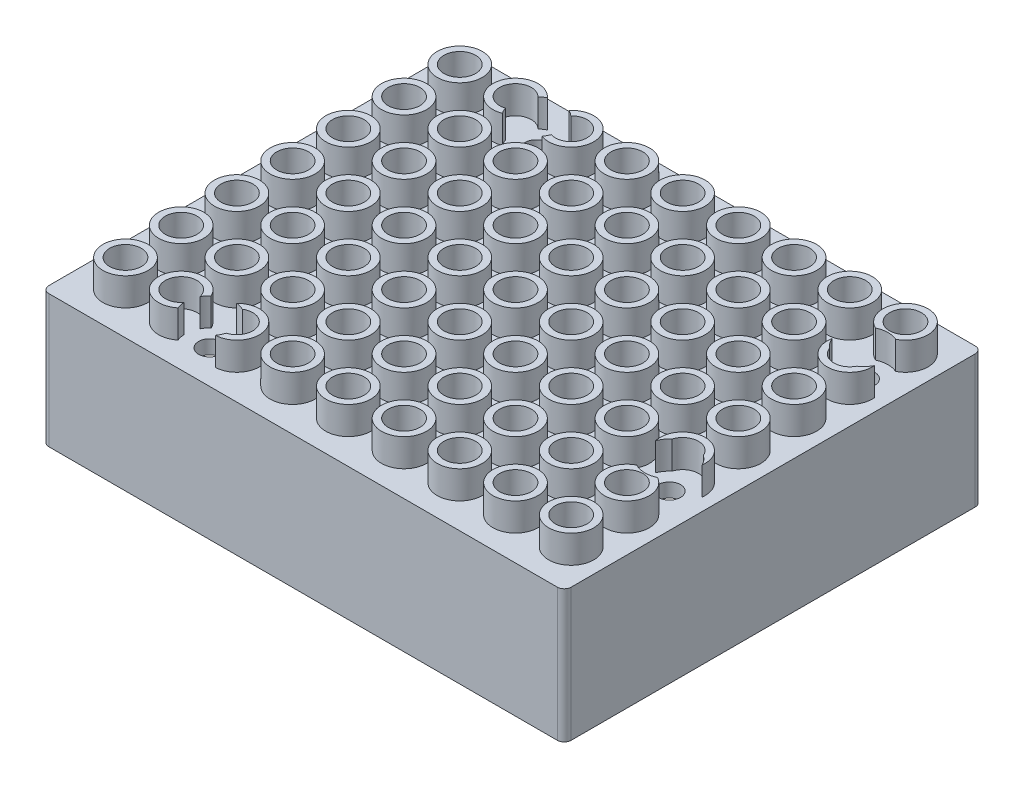
from build123d import *

# Parameters (mm, degrees)
SKETCH1_W                   = 75
SKETCH1_H                   = 60
BOSS_EXTRUDE1_DEPTH         = 19.05
FILLET1_R                   = 1
ARDUINO_START               = -2
ARDUINO_CAVITY_DEPTH        = 19.125
SKETCH4_R                   = 5.5
F_9V_BARREL_PLUG_HOLE_DEPTH = 19.125
SKETCH5_R                   = 3.2375
BUMP_1_DEPTH                = 4
SKETCH6_R                   = 2.275
CUT_EXTRUDE3_DEPTH          = 4
LPATTERN1_COUNT             = 7
LPATTERN1_PITCH             = 8
LPATTERN2_COUNT             = 9
LPATTERN2_PITCH             = 8
LPATTERN2_COPY_1_SKETCH_R   = 3.2375
LPATTERN2_COPY_1_DEPTH      = 4
LPATTERN2_COPY_2_SKETCH_R   = 3.2375
LPATTERN2_COPY_2_DEPTH      = 4
LPATTERN2_COPY_3_SKETCH_R   = 3.2375
LPATTERN2_COPY_3_DEPTH      = 4
LPATTERN2_COPY_4_SKETCH_R   = 3.2375
LPATTERN2_COPY_4_DEPTH      = 4
LPATTERN2_COPY_5_SKETCH_R   = 3.2375
LPATTERN2_COPY_5_DEPTH      = 4
LPATTERN2_COPY_6_SKETCH_R   = 3.2375
LPATTERN2_COPY_6_DEPTH      = 4
LPATTERN2_COPY_7_SKETCH_R   = 3.2375
LPATTERN2_COPY_7_DEPTH      = 4
LPATTERN2_COPY_8_SKETCH_R   = 3.2375
LPATTERN2_COPY_8_DEPTH      = 4
LPATTERN2_COPY_9_SKETCH_R   = 3.2375
LPATTERN2_COPY_9_DEPTH      = 4
LPATTERN2_COPY_10_SKETCH_R  = 3.2375
LPATTERN2_COPY_10_DEPTH     = 4
LPATTERN2_COPY_11_SKETCH_R  = 3.2375
LPATTERN2_COPY_11_DEPTH     = 4
LPATTERN2_COPY_12_SKETCH_R  = 3.2375
LPATTERN2_COPY_12_DEPTH     = 4
LPATTERN2_COPY_13_SKETCH_R  = 3.2375
LPATTERN2_COPY_13_DEPTH     = 4
LPATTERN2_COPY_14_SKETCH_R  = 3.2375
LPATTERN2_COPY_14_DEPTH     = 4
LPATTERN2_COPY_15_SKETCH_R  = 3.2375
LPATTERN2_COPY_15_DEPTH     = 4
LPATTERN2_COPY_16_SKETCH_R  = 3.2375
LPATTERN2_COPY_16_DEPTH     = 4
LPATTERN2_COPY_17_SKETCH_R  = 3.2375
LPATTERN2_COPY_17_DEPTH     = 4
LPATTERN2_COPY_18_SKETCH_R  = 3.2375
LPATTERN2_COPY_18_DEPTH     = 4
LPATTERN2_COPY_19_SKETCH_R  = 3.2375
LPATTERN2_COPY_19_DEPTH     = 4
LPATTERN2_COPY_20_SKETCH_R  = 3.2375
LPATTERN2_COPY_20_DEPTH     = 4
LPATTERN2_COPY_21_SKETCH_R  = 3.2375
LPATTERN2_COPY_21_DEPTH     = 4
LPATTERN2_COPY_22_SKETCH_R  = 3.2375
LPATTERN2_COPY_22_DEPTH     = 4
LPATTERN2_COPY_23_SKETCH_R  = 3.2375
LPATTERN2_COPY_23_DEPTH     = 4
LPATTERN2_COPY_24_SKETCH_R  = 3.2375
LPATTERN2_COPY_24_DEPTH     = 4
LPATTERN2_COPY_25_SKETCH_R  = 3.2375
LPATTERN2_COPY_25_DEPTH     = 4
LPATTERN2_COPY_26_SKETCH_R  = 3.2375
LPATTERN2_COPY_26_DEPTH     = 4
LPATTERN2_COPY_27_SKETCH_R  = 3.2375
LPATTERN2_COPY_27_DEPTH     = 4
LPATTERN2_COPY_28_SKETCH_R  = 3.2375
LPATTERN2_COPY_28_DEPTH     = 4
LPATTERN2_COPY_29_SKETCH_R  = 3.2375
LPATTERN2_COPY_29_DEPTH     = 4
LPATTERN2_COPY_30_SKETCH_R  = 3.2375
LPATTERN2_COPY_30_DEPTH     = 4
LPATTERN2_COPY_31_SKETCH_R  = 3.2375
LPATTERN2_COPY_31_DEPTH     = 4
LPATTERN2_COPY_32_SKETCH_R  = 3.2375
LPATTERN2_COPY_32_DEPTH     = 4
LPATTERN2_COPY_33_SKETCH_R  = 3.2375
LPATTERN2_COPY_33_DEPTH     = 4
LPATTERN2_COPY_34_SKETCH_R  = 3.2375
LPATTERN2_COPY_34_DEPTH     = 4
LPATTERN2_COPY_35_SKETCH_R  = 3.2375
LPATTERN2_COPY_35_DEPTH     = 4
LPATTERN2_COPY_36_SKETCH_R  = 3.2375
LPATTERN2_COPY_36_DEPTH     = 4
LPATTERN2_COPY_37_SKETCH_R  = 3.2375
LPATTERN2_COPY_37_DEPTH     = 4
LPATTERN2_COPY_38_SKETCH_R  = 3.2375
LPATTERN2_COPY_38_DEPTH     = 4
LPATTERN2_COPY_39_SKETCH_R  = 3.2375
LPATTERN2_COPY_39_DEPTH     = 4
LPATTERN2_COPY_40_SKETCH_R  = 3.2375
LPATTERN2_COPY_40_DEPTH     = 4
LPATTERN2_COPY_41_SKETCH_R  = 3.2375
LPATTERN2_COPY_41_DEPTH     = 4
LPATTERN2_COPY_42_SKETCH_R  = 3.2375
LPATTERN2_COPY_42_DEPTH     = 4
LPATTERN2_COPY_43_SKETCH_R  = 3.2375
LPATTERN2_COPY_43_DEPTH     = 4
LPATTERN2_COPY_44_SKETCH_R  = 3.2375
LPATTERN2_COPY_44_DEPTH     = 4
LPATTERN2_COPY_45_SKETCH_R  = 3.2375
LPATTERN2_COPY_45_DEPTH     = 4
LPATTERN2_COPY_46_SKETCH_R  = 3.2375
LPATTERN2_COPY_46_DEPTH     = 4
LPATTERN2_COPY_47_SKETCH_R  = 3.2375
LPATTERN2_COPY_47_DEPTH     = 4
LPATTERN2_COPY_48_SKETCH_R  = 3.2375
LPATTERN2_COPY_48_DEPTH     = 4
LPATTERN2_COPY_49_SKETCH_R  = 2.275
LPATTERN2_COPY_49_DEPTH     = 4
LPATTERN2_COPY_50_SKETCH_R  = 2.275
LPATTERN2_COPY_50_DEPTH     = 4
LPATTERN2_COPY_51_SKETCH_R  = 2.275
LPATTERN2_COPY_51_DEPTH     = 4
LPATTERN2_COPY_52_SKETCH_R  = 2.275
LPATTERN2_COPY_52_DEPTH     = 4
LPATTERN2_COPY_53_SKETCH_R  = 2.275
LPATTERN2_COPY_53_DEPTH     = 4
LPATTERN2_COPY_54_SKETCH_R  = 2.275
LPATTERN2_COPY_54_DEPTH     = 4
LPATTERN2_COPY_55_SKETCH_R  = 2.275
LPATTERN2_COPY_55_DEPTH     = 4
LPATTERN2_COPY_56_SKETCH_R  = 2.275
LPATTERN2_COPY_56_DEPTH     = 4
LPATTERN2_COPY_57_SKETCH_R  = 2.275
LPATTERN2_COPY_57_DEPTH     = 4
LPATTERN2_COPY_58_SKETCH_R  = 2.275
LPATTERN2_COPY_58_DEPTH     = 4
LPATTERN2_COPY_59_SKETCH_R  = 2.275
LPATTERN2_COPY_59_DEPTH     = 4
LPATTERN2_COPY_60_SKETCH_R  = 2.275
LPATTERN2_COPY_60_DEPTH     = 4
LPATTERN2_COPY_61_SKETCH_R  = 2.275
LPATTERN2_COPY_61_DEPTH     = 4
LPATTERN2_COPY_62_SKETCH_R  = 2.275
LPATTERN2_COPY_62_DEPTH     = 4
LPATTERN2_COPY_63_SKETCH_R  = 2.275
LPATTERN2_COPY_63_DEPTH     = 4
LPATTERN2_COPY_64_SKETCH_R  = 2.275
LPATTERN2_COPY_64_DEPTH     = 4
LPATTERN2_COPY_65_SKETCH_R  = 2.275
LPATTERN2_COPY_65_DEPTH     = 4
LPATTERN2_COPY_66_SKETCH_R  = 2.275
LPATTERN2_COPY_66_DEPTH     = 4
LPATTERN2_COPY_67_SKETCH_R  = 2.275
LPATTERN2_COPY_67_DEPTH     = 4
LPATTERN2_COPY_68_SKETCH_R  = 2.275
LPATTERN2_COPY_68_DEPTH     = 4
LPATTERN2_COPY_69_SKETCH_R  = 2.275
LPATTERN2_COPY_69_DEPTH     = 4
LPATTERN2_COPY_70_SKETCH_R  = 2.275
LPATTERN2_COPY_70_DEPTH     = 4
LPATTERN2_COPY_71_SKETCH_R  = 2.275
LPATTERN2_COPY_71_DEPTH     = 4
LPATTERN2_COPY_72_SKETCH_R  = 2.275
LPATTERN2_COPY_72_DEPTH     = 4
LPATTERN2_COPY_73_SKETCH_R  = 2.275
LPATTERN2_COPY_73_DEPTH     = 4
LPATTERN2_COPY_74_SKETCH_R  = 2.275
LPATTERN2_COPY_74_DEPTH     = 4
LPATTERN2_COPY_75_SKETCH_R  = 2.275
LPATTERN2_COPY_75_DEPTH     = 4
LPATTERN2_COPY_76_SKETCH_R  = 2.275
LPATTERN2_COPY_76_DEPTH     = 4
LPATTERN2_COPY_77_SKETCH_R  = 2.275
LPATTERN2_COPY_77_DEPTH     = 4
LPATTERN2_COPY_78_SKETCH_R  = 2.275
LPATTERN2_COPY_78_DEPTH     = 4
LPATTERN2_COPY_79_SKETCH_R  = 2.275
LPATTERN2_COPY_79_DEPTH     = 4
LPATTERN2_COPY_80_SKETCH_R  = 2.275
LPATTERN2_COPY_80_DEPTH     = 4
LPATTERN2_COPY_81_SKETCH_R  = 2.275
LPATTERN2_COPY_81_DEPTH     = 4
LPATTERN2_COPY_82_SKETCH_R  = 2.275
LPATTERN2_COPY_82_DEPTH     = 4
LPATTERN2_COPY_83_SKETCH_R  = 2.275
LPATTERN2_COPY_83_DEPTH     = 4
LPATTERN2_COPY_84_SKETCH_R  = 2.275
LPATTERN2_COPY_84_DEPTH     = 4
LPATTERN2_COPY_85_SKETCH_R  = 2.275
LPATTERN2_COPY_85_DEPTH     = 4
LPATTERN2_COPY_86_SKETCH_R  = 2.275
LPATTERN2_COPY_86_DEPTH     = 4
LPATTERN2_COPY_87_SKETCH_R  = 2.275
LPATTERN2_COPY_87_DEPTH     = 4
LPATTERN2_COPY_88_SKETCH_R  = 2.275
LPATTERN2_COPY_88_DEPTH     = 4
LPATTERN2_COPY_89_SKETCH_R  = 2.275
LPATTERN2_COPY_89_DEPTH     = 4
LPATTERN2_COPY_90_SKETCH_R  = 2.275
LPATTERN2_COPY_90_DEPTH     = 4
LPATTERN2_COPY_91_SKETCH_R  = 2.275
LPATTERN2_COPY_91_DEPTH     = 4
LPATTERN2_COPY_92_SKETCH_R  = 2.275
LPATTERN2_COPY_92_DEPTH     = 4
LPATTERN2_COPY_93_SKETCH_R  = 2.275
LPATTERN2_COPY_93_DEPTH     = 4
LPATTERN2_COPY_94_SKETCH_R  = 2.275
LPATTERN2_COPY_94_DEPTH     = 4
LPATTERN2_COPY_95_SKETCH_R  = 2.275
LPATTERN2_COPY_95_DEPTH     = 4
LPATTERN2_COPY_96_SKETCH_R  = 2.275
LPATTERN2_COPY_96_DEPTH     = 4
SKETCH2_R                   = 1.6
MOUNT_HOLES_DEPTH           = 1
MOUNT_HOLES_DEPTH_BACK      = 24.05
SKETCH7_R                   = 3.5
CUT_EXTRUDE4_DEPTH          = 4


with BuildPart() as part:
    # Sketch1 → Boss-Extrude1 (new body)
    with BuildSketch(Plane(origin=(0, 0, 0), x_dir=(1, 0, 0), z_dir=(0, 1, 0))):
        Rectangle(SKETCH1_W, SKETCH1_H)
    extrude(amount=BOSS_EXTRUDE1_DEPTH)

    # Fillet1
    fillet1_edges = [part.edges().sort_by_distance(p)[0] for p in [
        (37.5, 9.525, 30),
        (-37.5, 9.525, 30),
        (-37.5, 9.525, -30),
        (37.5, 9.525, -30),
    ]]
    fillet(fillet1_edges, radius=FILLET1_R)

    # Sketch3 → Arduino Cavity (cut)
    with BuildSketch(Plane(origin=(0, 19.05, 0), x_dir=(1, 0, 0), z_dir=(0, 1, 0)).offset(ARDUINO_START)):
        Polygon((-37.5, -18.85), (-34, -18.85), (-34, -28.25), (33.125, -28.25), (33.125, -15.25), (36, -12.375), (36, 20.375), (33.125, 23.25), (33.125, 26.75), (-34, 26.75), (-34, -6), (-37.5, -6), align=None)
    extrude(amount=-ARDUINO_CAVITY_DEPTH, mode=Mode.SUBTRACT)

    # Sketch4 → 9V Barrel Plug hole (cut)
    with BuildSketch(Plane.ZY.offset(37.5)):
        with Locations((-17.925, 6.4)):
            Circle(SKETCH4_R)
    extrude(amount=-F_9V_BARREL_PLUG_HOLE_DEPTH, mode=Mode.SUBTRACT)

    # Sketch5 → Bump 1 (add)
    with BuildSketch(Plane(origin=(0, 19.05, 0), x_dir=(1, 0, 0), z_dir=(0, 1, 0))):
        with Locations((-31.5, -24)):
            Circle(SKETCH5_R)
    bump_1 = extrude(amount=BUMP_1_DEPTH)

    # Sketch6 → Cut-Extrude3 (cut)
    with BuildSketch(Plane(origin=(0, 23.05, 0), x_dir=(1, 0, 0), z_dir=(0, 1, 0))):
        with Locations((-31.5, -24)):
            Circle(SKETCH6_R)
    cut_extrude3 = extrude(amount=-CUT_EXTRUDE3_DEPTH, mode=Mode.SUBTRACT)

    # LPattern1: Bump 1, Cut-Extrude3 ×7
    with Locations(*[(0, 0, -i * LPATTERN1_PITCH) for i in range(1, LPATTERN1_COUNT)]):
        add(bump_1)
        add(cut_extrude3, mode=Mode.SUBTRACT)

    # LPattern2: Bump 1, Cut-Extrude3 ×9
    with Locations(*[(i * LPATTERN2_PITCH, 0, 0) for i in range(1, LPATTERN2_COUNT)]):
        add(bump_1)
        add(cut_extrude3, mode=Mode.SUBTRACT)

    # LPattern2 copy 1 sketch → LPattern2 copy 1 (add)
    with BuildSketch(Plane(origin=(8, 19.05, -8), x_dir=(1, 0, 0), z_dir=(0, 1, 0))):
        with Locations((-31.5, -24)):
            Circle(LPATTERN2_COPY_1_SKETCH_R)
    extrude(amount=LPATTERN2_COPY_1_DEPTH)

    # LPattern2 copy 2 sketch → LPattern2 copy 2 (add)
    with BuildSketch(Plane(origin=(16, 19.05, -8), x_dir=(1, 0, 0), z_dir=(0, 1, 0))):
        with Locations((-31.5, -24)):
            Circle(LPATTERN2_COPY_2_SKETCH_R)
    extrude(amount=LPATTERN2_COPY_2_DEPTH)

    # LPattern2 copy 3 sketch → LPattern2 copy 3 (add)
    with BuildSketch(Plane(origin=(24, 19.05, -8), x_dir=(1, 0, 0), z_dir=(0, 1, 0))):
        with Locations((-31.5, -24)):
            Circle(LPATTERN2_COPY_3_SKETCH_R)
    extrude(amount=LPATTERN2_COPY_3_DEPTH)

    # LPattern2 copy 4 sketch → LPattern2 copy 4 (add)
    with BuildSketch(Plane(origin=(32, 19.05, -8), x_dir=(1, 0, 0), z_dir=(0, 1, 0))):
        with Locations((-31.5, -24)):
            Circle(LPATTERN2_COPY_4_SKETCH_R)
    extrude(amount=LPATTERN2_COPY_4_DEPTH)

    # LPattern2 copy 5 sketch → LPattern2 copy 5 (add)
    with BuildSketch(Plane(origin=(40, 19.05, -8), x_dir=(1, 0, 0), z_dir=(0, 1, 0))):
        with Locations((-31.5, -24)):
            Circle(LPATTERN2_COPY_5_SKETCH_R)
    extrude(amount=LPATTERN2_COPY_5_DEPTH)

    # LPattern2 copy 6 sketch → LPattern2 copy 6 (add)
    with BuildSketch(Plane(origin=(48, 19.05, -8), x_dir=(1, 0, 0), z_dir=(0, 1, 0))):
        with Locations((-31.5, -24)):
            Circle(LPATTERN2_COPY_6_SKETCH_R)
    extrude(amount=LPATTERN2_COPY_6_DEPTH)

    # LPattern2 copy 7 sketch → LPattern2 copy 7 (add)
    with BuildSketch(Plane(origin=(56, 19.05, -8), x_dir=(1, 0, 0), z_dir=(0, 1, 0))):
        with Locations((-31.5, -24)):
            Circle(LPATTERN2_COPY_7_SKETCH_R)
    extrude(amount=LPATTERN2_COPY_7_DEPTH)

    # LPattern2 copy 8 sketch → LPattern2 copy 8 (add)
    with BuildSketch(Plane(origin=(64, 19.05, -8), x_dir=(1, 0, 0), z_dir=(0, 1, 0))):
        with Locations((-31.5, -24)):
            Circle(LPATTERN2_COPY_8_SKETCH_R)
    extrude(amount=LPATTERN2_COPY_8_DEPTH)

    # LPattern2 copy 9 sketch → LPattern2 copy 9 (add)
    with BuildSketch(Plane(origin=(8, 19.05, -16), x_dir=(1, 0, 0), z_dir=(0, 1, 0))):
        with Locations((-31.5, -24)):
            Circle(LPATTERN2_COPY_9_SKETCH_R)
    extrude(amount=LPATTERN2_COPY_9_DEPTH)

    # LPattern2 copy 10 sketch → LPattern2 copy 10 (add)
    with BuildSketch(Plane(origin=(16, 19.05, -16), x_dir=(1, 0, 0), z_dir=(0, 1, 0))):
        with Locations((-31.5, -24)):
            Circle(LPATTERN2_COPY_10_SKETCH_R)
    extrude(amount=LPATTERN2_COPY_10_DEPTH)

    # LPattern2 copy 11 sketch → LPattern2 copy 11 (add)
    with BuildSketch(Plane(origin=(24, 19.05, -16), x_dir=(1, 0, 0), z_dir=(0, 1, 0))):
        with Locations((-31.5, -24)):
            Circle(LPATTERN2_COPY_11_SKETCH_R)
    extrude(amount=LPATTERN2_COPY_11_DEPTH)

    # LPattern2 copy 12 sketch → LPattern2 copy 12 (add)
    with BuildSketch(Plane(origin=(32, 19.05, -16), x_dir=(1, 0, 0), z_dir=(0, 1, 0))):
        with Locations((-31.5, -24)):
            Circle(LPATTERN2_COPY_12_SKETCH_R)
    extrude(amount=LPATTERN2_COPY_12_DEPTH)

    # LPattern2 copy 13 sketch → LPattern2 copy 13 (add)
    with BuildSketch(Plane(origin=(40, 19.05, -16), x_dir=(1, 0, 0), z_dir=(0, 1, 0))):
        with Locations((-31.5, -24)):
            Circle(LPATTERN2_COPY_13_SKETCH_R)
    extrude(amount=LPATTERN2_COPY_13_DEPTH)

    # LPattern2 copy 14 sketch → LPattern2 copy 14 (add)
    with BuildSketch(Plane(origin=(48, 19.05, -16), x_dir=(1, 0, 0), z_dir=(0, 1, 0))):
        with Locations((-31.5, -24)):
            Circle(LPATTERN2_COPY_14_SKETCH_R)
    extrude(amount=LPATTERN2_COPY_14_DEPTH)

    # LPattern2 copy 15 sketch → LPattern2 copy 15 (add)
    with BuildSketch(Plane(origin=(56, 19.05, -16), x_dir=(1, 0, 0), z_dir=(0, 1, 0))):
        with Locations((-31.5, -24)):
            Circle(LPATTERN2_COPY_15_SKETCH_R)
    extrude(amount=LPATTERN2_COPY_15_DEPTH)

    # LPattern2 copy 16 sketch → LPattern2 copy 16 (add)
    with BuildSketch(Plane(origin=(64, 19.05, -16), x_dir=(1, 0, 0), z_dir=(0, 1, 0))):
        with Locations((-31.5, -24)):
            Circle(LPATTERN2_COPY_16_SKETCH_R)
    extrude(amount=LPATTERN2_COPY_16_DEPTH)

    # LPattern2 copy 17 sketch → LPattern2 copy 17 (add)
    with BuildSketch(Plane(origin=(8, 19.05, -24), x_dir=(1, 0, 0), z_dir=(0, 1, 0))):
        with Locations((-31.5, -24)):
            Circle(LPATTERN2_COPY_17_SKETCH_R)
    extrude(amount=LPATTERN2_COPY_17_DEPTH)

    # LPattern2 copy 18 sketch → LPattern2 copy 18 (add)
    with BuildSketch(Plane(origin=(16, 19.05, -24), x_dir=(1, 0, 0), z_dir=(0, 1, 0))):
        with Locations((-31.5, -24)):
            Circle(LPATTERN2_COPY_18_SKETCH_R)
    extrude(amount=LPATTERN2_COPY_18_DEPTH)

    # LPattern2 copy 19 sketch → LPattern2 copy 19 (add)
    with BuildSketch(Plane(origin=(24, 19.05, -24), x_dir=(1, 0, 0), z_dir=(0, 1, 0))):
        with Locations((-31.5, -24)):
            Circle(LPATTERN2_COPY_19_SKETCH_R)
    extrude(amount=LPATTERN2_COPY_19_DEPTH)

    # LPattern2 copy 20 sketch → LPattern2 copy 20 (add)
    with BuildSketch(Plane(origin=(32, 19.05, -24), x_dir=(1, 0, 0), z_dir=(0, 1, 0))):
        with Locations((-31.5, -24)):
            Circle(LPATTERN2_COPY_20_SKETCH_R)
    extrude(amount=LPATTERN2_COPY_20_DEPTH)

    # LPattern2 copy 21 sketch → LPattern2 copy 21 (add)
    with BuildSketch(Plane(origin=(40, 19.05, -24), x_dir=(1, 0, 0), z_dir=(0, 1, 0))):
        with Locations((-31.5, -24)):
            Circle(LPATTERN2_COPY_21_SKETCH_R)
    extrude(amount=LPATTERN2_COPY_21_DEPTH)

    # LPattern2 copy 22 sketch → LPattern2 copy 22 (add)
    with BuildSketch(Plane(origin=(48, 19.05, -24), x_dir=(1, 0, 0), z_dir=(0, 1, 0))):
        with Locations((-31.5, -24)):
            Circle(LPATTERN2_COPY_22_SKETCH_R)
    extrude(amount=LPATTERN2_COPY_22_DEPTH)

    # LPattern2 copy 23 sketch → LPattern2 copy 23 (add)
    with BuildSketch(Plane(origin=(56, 19.05, -24), x_dir=(1, 0, 0), z_dir=(0, 1, 0))):
        with Locations((-31.5, -24)):
            Circle(LPATTERN2_COPY_23_SKETCH_R)
    extrude(amount=LPATTERN2_COPY_23_DEPTH)

    # LPattern2 copy 24 sketch → LPattern2 copy 24 (add)
    with BuildSketch(Plane(origin=(64, 19.05, -24), x_dir=(1, 0, 0), z_dir=(0, 1, 0))):
        with Locations((-31.5, -24)):
            Circle(LPATTERN2_COPY_24_SKETCH_R)
    extrude(amount=LPATTERN2_COPY_24_DEPTH)

    # LPattern2 copy 25 sketch → LPattern2 copy 25 (add)
    with BuildSketch(Plane(origin=(8, 19.05, -32), x_dir=(1, 0, 0), z_dir=(0, 1, 0))):
        with Locations((-31.5, -24)):
            Circle(LPATTERN2_COPY_25_SKETCH_R)
    extrude(amount=LPATTERN2_COPY_25_DEPTH)

    # LPattern2 copy 26 sketch → LPattern2 copy 26 (add)
    with BuildSketch(Plane(origin=(16, 19.05, -32), x_dir=(1, 0, 0), z_dir=(0, 1, 0))):
        with Locations((-31.5, -24)):
            Circle(LPATTERN2_COPY_26_SKETCH_R)
    extrude(amount=LPATTERN2_COPY_26_DEPTH)

    # LPattern2 copy 27 sketch → LPattern2 copy 27 (add)
    with BuildSketch(Plane(origin=(24, 19.05, -32), x_dir=(1, 0, 0), z_dir=(0, 1, 0))):
        with Locations((-31.5, -24)):
            Circle(LPATTERN2_COPY_27_SKETCH_R)
    extrude(amount=LPATTERN2_COPY_27_DEPTH)

    # LPattern2 copy 28 sketch → LPattern2 copy 28 (add)
    with BuildSketch(Plane(origin=(32, 19.05, -32), x_dir=(1, 0, 0), z_dir=(0, 1, 0))):
        with Locations((-31.5, -24)):
            Circle(LPATTERN2_COPY_28_SKETCH_R)
    extrude(amount=LPATTERN2_COPY_28_DEPTH)

    # LPattern2 copy 29 sketch → LPattern2 copy 29 (add)
    with BuildSketch(Plane(origin=(40, 19.05, -32), x_dir=(1, 0, 0), z_dir=(0, 1, 0))):
        with Locations((-31.5, -24)):
            Circle(LPATTERN2_COPY_29_SKETCH_R)
    extrude(amount=LPATTERN2_COPY_29_DEPTH)

    # LPattern2 copy 30 sketch → LPattern2 copy 30 (add)
    with BuildSketch(Plane(origin=(48, 19.05, -32), x_dir=(1, 0, 0), z_dir=(0, 1, 0))):
        with Locations((-31.5, -24)):
            Circle(LPATTERN2_COPY_30_SKETCH_R)
    extrude(amount=LPATTERN2_COPY_30_DEPTH)

    # LPattern2 copy 31 sketch → LPattern2 copy 31 (add)
    with BuildSketch(Plane(origin=(56, 19.05, -32), x_dir=(1, 0, 0), z_dir=(0, 1, 0))):
        with Locations((-31.5, -24)):
            Circle(LPATTERN2_COPY_31_SKETCH_R)
    extrude(amount=LPATTERN2_COPY_31_DEPTH)

    # LPattern2 copy 32 sketch → LPattern2 copy 32 (add)
    with BuildSketch(Plane(origin=(64, 19.05, -32), x_dir=(1, 0, 0), z_dir=(0, 1, 0))):
        with Locations((-31.5, -24)):
            Circle(LPATTERN2_COPY_32_SKETCH_R)
    extrude(amount=LPATTERN2_COPY_32_DEPTH)

    # LPattern2 copy 33 sketch → LPattern2 copy 33 (add)
    with BuildSketch(Plane(origin=(8, 19.05, -40), x_dir=(1, 0, 0), z_dir=(0, 1, 0))):
        with Locations((-31.5, -24)):
            Circle(LPATTERN2_COPY_33_SKETCH_R)
    extrude(amount=LPATTERN2_COPY_33_DEPTH)

    # LPattern2 copy 34 sketch → LPattern2 copy 34 (add)
    with BuildSketch(Plane(origin=(16, 19.05, -40), x_dir=(1, 0, 0), z_dir=(0, 1, 0))):
        with Locations((-31.5, -24)):
            Circle(LPATTERN2_COPY_34_SKETCH_R)
    extrude(amount=LPATTERN2_COPY_34_DEPTH)

    # LPattern2 copy 35 sketch → LPattern2 copy 35 (add)
    with BuildSketch(Plane(origin=(24, 19.05, -40), x_dir=(1, 0, 0), z_dir=(0, 1, 0))):
        with Locations((-31.5, -24)):
            Circle(LPATTERN2_COPY_35_SKETCH_R)
    extrude(amount=LPATTERN2_COPY_35_DEPTH)

    # LPattern2 copy 36 sketch → LPattern2 copy 36 (add)
    with BuildSketch(Plane(origin=(32, 19.05, -40), x_dir=(1, 0, 0), z_dir=(0, 1, 0))):
        with Locations((-31.5, -24)):
            Circle(LPATTERN2_COPY_36_SKETCH_R)
    extrude(amount=LPATTERN2_COPY_36_DEPTH)

    # LPattern2 copy 37 sketch → LPattern2 copy 37 (add)
    with BuildSketch(Plane(origin=(40, 19.05, -40), x_dir=(1, 0, 0), z_dir=(0, 1, 0))):
        with Locations((-31.5, -24)):
            Circle(LPATTERN2_COPY_37_SKETCH_R)
    extrude(amount=LPATTERN2_COPY_37_DEPTH)

    # LPattern2 copy 38 sketch → LPattern2 copy 38 (add)
    with BuildSketch(Plane(origin=(48, 19.05, -40), x_dir=(1, 0, 0), z_dir=(0, 1, 0))):
        with Locations((-31.5, -24)):
            Circle(LPATTERN2_COPY_38_SKETCH_R)
    extrude(amount=LPATTERN2_COPY_38_DEPTH)

    # LPattern2 copy 39 sketch → LPattern2 copy 39 (add)
    with BuildSketch(Plane(origin=(56, 19.05, -40), x_dir=(1, 0, 0), z_dir=(0, 1, 0))):
        with Locations((-31.5, -24)):
            Circle(LPATTERN2_COPY_39_SKETCH_R)
    extrude(amount=LPATTERN2_COPY_39_DEPTH)

    # LPattern2 copy 40 sketch → LPattern2 copy 40 (add)
    with BuildSketch(Plane(origin=(64, 19.05, -40), x_dir=(1, 0, 0), z_dir=(0, 1, 0))):
        with Locations((-31.5, -24)):
            Circle(LPATTERN2_COPY_40_SKETCH_R)
    extrude(amount=LPATTERN2_COPY_40_DEPTH)

    # LPattern2 copy 41 sketch → LPattern2 copy 41 (add)
    with BuildSketch(Plane(origin=(8, 19.05, -48), x_dir=(1, 0, 0), z_dir=(0, 1, 0))):
        with Locations((-31.5, -24)):
            Circle(LPATTERN2_COPY_41_SKETCH_R)
    extrude(amount=LPATTERN2_COPY_41_DEPTH)

    # LPattern2 copy 42 sketch → LPattern2 copy 42 (add)
    with BuildSketch(Plane(origin=(16, 19.05, -48), x_dir=(1, 0, 0), z_dir=(0, 1, 0))):
        with Locations((-31.5, -24)):
            Circle(LPATTERN2_COPY_42_SKETCH_R)
    extrude(amount=LPATTERN2_COPY_42_DEPTH)

    # LPattern2 copy 43 sketch → LPattern2 copy 43 (add)
    with BuildSketch(Plane(origin=(24, 19.05, -48), x_dir=(1, 0, 0), z_dir=(0, 1, 0))):
        with Locations((-31.5, -24)):
            Circle(LPATTERN2_COPY_43_SKETCH_R)
    extrude(amount=LPATTERN2_COPY_43_DEPTH)

    # LPattern2 copy 44 sketch → LPattern2 copy 44 (add)
    with BuildSketch(Plane(origin=(32, 19.05, -48), x_dir=(1, 0, 0), z_dir=(0, 1, 0))):
        with Locations((-31.5, -24)):
            Circle(LPATTERN2_COPY_44_SKETCH_R)
    extrude(amount=LPATTERN2_COPY_44_DEPTH)

    # LPattern2 copy 45 sketch → LPattern2 copy 45 (add)
    with BuildSketch(Plane(origin=(40, 19.05, -48), x_dir=(1, 0, 0), z_dir=(0, 1, 0))):
        with Locations((-31.5, -24)):
            Circle(LPATTERN2_COPY_45_SKETCH_R)
    extrude(amount=LPATTERN2_COPY_45_DEPTH)

    # LPattern2 copy 46 sketch → LPattern2 copy 46 (add)
    with BuildSketch(Plane(origin=(48, 19.05, -48), x_dir=(1, 0, 0), z_dir=(0, 1, 0))):
        with Locations((-31.5, -24)):
            Circle(LPATTERN2_COPY_46_SKETCH_R)
    extrude(amount=LPATTERN2_COPY_46_DEPTH)

    # LPattern2 copy 47 sketch → LPattern2 copy 47 (add)
    with BuildSketch(Plane(origin=(56, 19.05, -48), x_dir=(1, 0, 0), z_dir=(0, 1, 0))):
        with Locations((-31.5, -24)):
            Circle(LPATTERN2_COPY_47_SKETCH_R)
    extrude(amount=LPATTERN2_COPY_47_DEPTH)

    # LPattern2 copy 48 sketch → LPattern2 copy 48 (add)
    with BuildSketch(Plane(origin=(64, 19.05, -48), x_dir=(1, 0, 0), z_dir=(0, 1, 0))):
        with Locations((-31.5, -24)):
            Circle(LPATTERN2_COPY_48_SKETCH_R)
    extrude(amount=LPATTERN2_COPY_48_DEPTH)

    # LPattern2 copy 49 sketch → LPattern2 copy 49 (cut)
    with BuildSketch(Plane(origin=(8, 23.05, -8), x_dir=(1, 0, 0), z_dir=(0, 1, 0))):
        with Locations((-31.5, -24)):
            Circle(LPATTERN2_COPY_49_SKETCH_R)
    extrude(amount=-LPATTERN2_COPY_49_DEPTH, mode=Mode.SUBTRACT)

    # LPattern2 copy 50 sketch → LPattern2 copy 50 (cut)
    with BuildSketch(Plane(origin=(16, 23.05, -8), x_dir=(1, 0, 0), z_dir=(0, 1, 0))):
        with Locations((-31.5, -24)):
            Circle(LPATTERN2_COPY_50_SKETCH_R)
    extrude(amount=-LPATTERN2_COPY_50_DEPTH, mode=Mode.SUBTRACT)

    # LPattern2 copy 51 sketch → LPattern2 copy 51 (cut)
    with BuildSketch(Plane(origin=(24, 23.05, -8), x_dir=(1, 0, 0), z_dir=(0, 1, 0))):
        with Locations((-31.5, -24)):
            Circle(LPATTERN2_COPY_51_SKETCH_R)
    extrude(amount=-LPATTERN2_COPY_51_DEPTH, mode=Mode.SUBTRACT)

    # LPattern2 copy 52 sketch → LPattern2 copy 52 (cut)
    with BuildSketch(Plane(origin=(32, 23.05, -8), x_dir=(1, 0, 0), z_dir=(0, 1, 0))):
        with Locations((-31.5, -24)):
            Circle(LPATTERN2_COPY_52_SKETCH_R)
    extrude(amount=-LPATTERN2_COPY_52_DEPTH, mode=Mode.SUBTRACT)

    # LPattern2 copy 53 sketch → LPattern2 copy 53 (cut)
    with BuildSketch(Plane(origin=(40, 23.05, -8), x_dir=(1, 0, 0), z_dir=(0, 1, 0))):
        with Locations((-31.5, -24)):
            Circle(LPATTERN2_COPY_53_SKETCH_R)
    extrude(amount=-LPATTERN2_COPY_53_DEPTH, mode=Mode.SUBTRACT)

    # LPattern2 copy 54 sketch → LPattern2 copy 54 (cut)
    with BuildSketch(Plane(origin=(48, 23.05, -8), x_dir=(1, 0, 0), z_dir=(0, 1, 0))):
        with Locations((-31.5, -24)):
            Circle(LPATTERN2_COPY_54_SKETCH_R)
    extrude(amount=-LPATTERN2_COPY_54_DEPTH, mode=Mode.SUBTRACT)

    # LPattern2 copy 55 sketch → LPattern2 copy 55 (cut)
    with BuildSketch(Plane(origin=(56, 23.05, -8), x_dir=(1, 0, 0), z_dir=(0, 1, 0))):
        with Locations((-31.5, -24)):
            Circle(LPATTERN2_COPY_55_SKETCH_R)
    extrude(amount=-LPATTERN2_COPY_55_DEPTH, mode=Mode.SUBTRACT)

    # LPattern2 copy 56 sketch → LPattern2 copy 56 (cut)
    with BuildSketch(Plane(origin=(64, 23.05, -8), x_dir=(1, 0, 0), z_dir=(0, 1, 0))):
        with Locations((-31.5, -24)):
            Circle(LPATTERN2_COPY_56_SKETCH_R)
    extrude(amount=-LPATTERN2_COPY_56_DEPTH, mode=Mode.SUBTRACT)

    # LPattern2 copy 57 sketch → LPattern2 copy 57 (cut)
    with BuildSketch(Plane(origin=(8, 23.05, -16), x_dir=(1, 0, 0), z_dir=(0, 1, 0))):
        with Locations((-31.5, -24)):
            Circle(LPATTERN2_COPY_57_SKETCH_R)
    extrude(amount=-LPATTERN2_COPY_57_DEPTH, mode=Mode.SUBTRACT)

    # LPattern2 copy 58 sketch → LPattern2 copy 58 (cut)
    with BuildSketch(Plane(origin=(16, 23.05, -16), x_dir=(1, 0, 0), z_dir=(0, 1, 0))):
        with Locations((-31.5, -24)):
            Circle(LPATTERN2_COPY_58_SKETCH_R)
    extrude(amount=-LPATTERN2_COPY_58_DEPTH, mode=Mode.SUBTRACT)

    # LPattern2 copy 59 sketch → LPattern2 copy 59 (cut)
    with BuildSketch(Plane(origin=(24, 23.05, -16), x_dir=(1, 0, 0), z_dir=(0, 1, 0))):
        with Locations((-31.5, -24)):
            Circle(LPATTERN2_COPY_59_SKETCH_R)
    extrude(amount=-LPATTERN2_COPY_59_DEPTH, mode=Mode.SUBTRACT)

    # LPattern2 copy 60 sketch → LPattern2 copy 60 (cut)
    with BuildSketch(Plane(origin=(32, 23.05, -16), x_dir=(1, 0, 0), z_dir=(0, 1, 0))):
        with Locations((-31.5, -24)):
            Circle(LPATTERN2_COPY_60_SKETCH_R)
    extrude(amount=-LPATTERN2_COPY_60_DEPTH, mode=Mode.SUBTRACT)

    # LPattern2 copy 61 sketch → LPattern2 copy 61 (cut)
    with BuildSketch(Plane(origin=(40, 23.05, -16), x_dir=(1, 0, 0), z_dir=(0, 1, 0))):
        with Locations((-31.5, -24)):
            Circle(LPATTERN2_COPY_61_SKETCH_R)
    extrude(amount=-LPATTERN2_COPY_61_DEPTH, mode=Mode.SUBTRACT)

    # LPattern2 copy 62 sketch → LPattern2 copy 62 (cut)
    with BuildSketch(Plane(origin=(48, 23.05, -16), x_dir=(1, 0, 0), z_dir=(0, 1, 0))):
        with Locations((-31.5, -24)):
            Circle(LPATTERN2_COPY_62_SKETCH_R)
    extrude(amount=-LPATTERN2_COPY_62_DEPTH, mode=Mode.SUBTRACT)

    # LPattern2 copy 63 sketch → LPattern2 copy 63 (cut)
    with BuildSketch(Plane(origin=(56, 23.05, -16), x_dir=(1, 0, 0), z_dir=(0, 1, 0))):
        with Locations((-31.5, -24)):
            Circle(LPATTERN2_COPY_63_SKETCH_R)
    extrude(amount=-LPATTERN2_COPY_63_DEPTH, mode=Mode.SUBTRACT)

    # LPattern2 copy 64 sketch → LPattern2 copy 64 (cut)
    with BuildSketch(Plane(origin=(64, 23.05, -16), x_dir=(1, 0, 0), z_dir=(0, 1, 0))):
        with Locations((-31.5, -24)):
            Circle(LPATTERN2_COPY_64_SKETCH_R)
    extrude(amount=-LPATTERN2_COPY_64_DEPTH, mode=Mode.SUBTRACT)

    # LPattern2 copy 65 sketch → LPattern2 copy 65 (cut)
    with BuildSketch(Plane(origin=(8, 23.05, -24), x_dir=(1, 0, 0), z_dir=(0, 1, 0))):
        with Locations((-31.5, -24)):
            Circle(LPATTERN2_COPY_65_SKETCH_R)
    extrude(amount=-LPATTERN2_COPY_65_DEPTH, mode=Mode.SUBTRACT)

    # LPattern2 copy 66 sketch → LPattern2 copy 66 (cut)
    with BuildSketch(Plane(origin=(16, 23.05, -24), x_dir=(1, 0, 0), z_dir=(0, 1, 0))):
        with Locations((-31.5, -24)):
            Circle(LPATTERN2_COPY_66_SKETCH_R)
    extrude(amount=-LPATTERN2_COPY_66_DEPTH, mode=Mode.SUBTRACT)

    # LPattern2 copy 67 sketch → LPattern2 copy 67 (cut)
    with BuildSketch(Plane(origin=(24, 23.05, -24), x_dir=(1, 0, 0), z_dir=(0, 1, 0))):
        with Locations((-31.5, -24)):
            Circle(LPATTERN2_COPY_67_SKETCH_R)
    extrude(amount=-LPATTERN2_COPY_67_DEPTH, mode=Mode.SUBTRACT)

    # LPattern2 copy 68 sketch → LPattern2 copy 68 (cut)
    with BuildSketch(Plane(origin=(32, 23.05, -24), x_dir=(1, 0, 0), z_dir=(0, 1, 0))):
        with Locations((-31.5, -24)):
            Circle(LPATTERN2_COPY_68_SKETCH_R)
    extrude(amount=-LPATTERN2_COPY_68_DEPTH, mode=Mode.SUBTRACT)

    # LPattern2 copy 69 sketch → LPattern2 copy 69 (cut)
    with BuildSketch(Plane(origin=(40, 23.05, -24), x_dir=(1, 0, 0), z_dir=(0, 1, 0))):
        with Locations((-31.5, -24)):
            Circle(LPATTERN2_COPY_69_SKETCH_R)
    extrude(amount=-LPATTERN2_COPY_69_DEPTH, mode=Mode.SUBTRACT)

    # LPattern2 copy 70 sketch → LPattern2 copy 70 (cut)
    with BuildSketch(Plane(origin=(48, 23.05, -24), x_dir=(1, 0, 0), z_dir=(0, 1, 0))):
        with Locations((-31.5, -24)):
            Circle(LPATTERN2_COPY_70_SKETCH_R)
    extrude(amount=-LPATTERN2_COPY_70_DEPTH, mode=Mode.SUBTRACT)

    # LPattern2 copy 71 sketch → LPattern2 copy 71 (cut)
    with BuildSketch(Plane(origin=(56, 23.05, -24), x_dir=(1, 0, 0), z_dir=(0, 1, 0))):
        with Locations((-31.5, -24)):
            Circle(LPATTERN2_COPY_71_SKETCH_R)
    extrude(amount=-LPATTERN2_COPY_71_DEPTH, mode=Mode.SUBTRACT)

    # LPattern2 copy 72 sketch → LPattern2 copy 72 (cut)
    with BuildSketch(Plane(origin=(64, 23.05, -24), x_dir=(1, 0, 0), z_dir=(0, 1, 0))):
        with Locations((-31.5, -24)):
            Circle(LPATTERN2_COPY_72_SKETCH_R)
    extrude(amount=-LPATTERN2_COPY_72_DEPTH, mode=Mode.SUBTRACT)

    # LPattern2 copy 73 sketch → LPattern2 copy 73 (cut)
    with BuildSketch(Plane(origin=(8, 23.05, -32), x_dir=(1, 0, 0), z_dir=(0, 1, 0))):
        with Locations((-31.5, -24)):
            Circle(LPATTERN2_COPY_73_SKETCH_R)
    extrude(amount=-LPATTERN2_COPY_73_DEPTH, mode=Mode.SUBTRACT)

    # LPattern2 copy 74 sketch → LPattern2 copy 74 (cut)
    with BuildSketch(Plane(origin=(16, 23.05, -32), x_dir=(1, 0, 0), z_dir=(0, 1, 0))):
        with Locations((-31.5, -24)):
            Circle(LPATTERN2_COPY_74_SKETCH_R)
    extrude(amount=-LPATTERN2_COPY_74_DEPTH, mode=Mode.SUBTRACT)

    # LPattern2 copy 75 sketch → LPattern2 copy 75 (cut)
    with BuildSketch(Plane(origin=(24, 23.05, -32), x_dir=(1, 0, 0), z_dir=(0, 1, 0))):
        with Locations((-31.5, -24)):
            Circle(LPATTERN2_COPY_75_SKETCH_R)
    extrude(amount=-LPATTERN2_COPY_75_DEPTH, mode=Mode.SUBTRACT)

    # LPattern2 copy 76 sketch → LPattern2 copy 76 (cut)
    with BuildSketch(Plane(origin=(32, 23.05, -32), x_dir=(1, 0, 0), z_dir=(0, 1, 0))):
        with Locations((-31.5, -24)):
            Circle(LPATTERN2_COPY_76_SKETCH_R)
    extrude(amount=-LPATTERN2_COPY_76_DEPTH, mode=Mode.SUBTRACT)

    # LPattern2 copy 77 sketch → LPattern2 copy 77 (cut)
    with BuildSketch(Plane(origin=(40, 23.05, -32), x_dir=(1, 0, 0), z_dir=(0, 1, 0))):
        with Locations((-31.5, -24)):
            Circle(LPATTERN2_COPY_77_SKETCH_R)
    extrude(amount=-LPATTERN2_COPY_77_DEPTH, mode=Mode.SUBTRACT)

    # LPattern2 copy 78 sketch → LPattern2 copy 78 (cut)
    with BuildSketch(Plane(origin=(48, 23.05, -32), x_dir=(1, 0, 0), z_dir=(0, 1, 0))):
        with Locations((-31.5, -24)):
            Circle(LPATTERN2_COPY_78_SKETCH_R)
    extrude(amount=-LPATTERN2_COPY_78_DEPTH, mode=Mode.SUBTRACT)

    # LPattern2 copy 79 sketch → LPattern2 copy 79 (cut)
    with BuildSketch(Plane(origin=(56, 23.05, -32), x_dir=(1, 0, 0), z_dir=(0, 1, 0))):
        with Locations((-31.5, -24)):
            Circle(LPATTERN2_COPY_79_SKETCH_R)
    extrude(amount=-LPATTERN2_COPY_79_DEPTH, mode=Mode.SUBTRACT)

    # LPattern2 copy 80 sketch → LPattern2 copy 80 (cut)
    with BuildSketch(Plane(origin=(64, 23.05, -32), x_dir=(1, 0, 0), z_dir=(0, 1, 0))):
        with Locations((-31.5, -24)):
            Circle(LPATTERN2_COPY_80_SKETCH_R)
    extrude(amount=-LPATTERN2_COPY_80_DEPTH, mode=Mode.SUBTRACT)

    # LPattern2 copy 81 sketch → LPattern2 copy 81 (cut)
    with BuildSketch(Plane(origin=(8, 23.05, -40), x_dir=(1, 0, 0), z_dir=(0, 1, 0))):
        with Locations((-31.5, -24)):
            Circle(LPATTERN2_COPY_81_SKETCH_R)
    extrude(amount=-LPATTERN2_COPY_81_DEPTH, mode=Mode.SUBTRACT)

    # LPattern2 copy 82 sketch → LPattern2 copy 82 (cut)
    with BuildSketch(Plane(origin=(16, 23.05, -40), x_dir=(1, 0, 0), z_dir=(0, 1, 0))):
        with Locations((-31.5, -24)):
            Circle(LPATTERN2_COPY_82_SKETCH_R)
    extrude(amount=-LPATTERN2_COPY_82_DEPTH, mode=Mode.SUBTRACT)

    # LPattern2 copy 83 sketch → LPattern2 copy 83 (cut)
    with BuildSketch(Plane(origin=(24, 23.05, -40), x_dir=(1, 0, 0), z_dir=(0, 1, 0))):
        with Locations((-31.5, -24)):
            Circle(LPATTERN2_COPY_83_SKETCH_R)
    extrude(amount=-LPATTERN2_COPY_83_DEPTH, mode=Mode.SUBTRACT)

    # LPattern2 copy 84 sketch → LPattern2 copy 84 (cut)
    with BuildSketch(Plane(origin=(32, 23.05, -40), x_dir=(1, 0, 0), z_dir=(0, 1, 0))):
        with Locations((-31.5, -24)):
            Circle(LPATTERN2_COPY_84_SKETCH_R)
    extrude(amount=-LPATTERN2_COPY_84_DEPTH, mode=Mode.SUBTRACT)

    # LPattern2 copy 85 sketch → LPattern2 copy 85 (cut)
    with BuildSketch(Plane(origin=(40, 23.05, -40), x_dir=(1, 0, 0), z_dir=(0, 1, 0))):
        with Locations((-31.5, -24)):
            Circle(LPATTERN2_COPY_85_SKETCH_R)
    extrude(amount=-LPATTERN2_COPY_85_DEPTH, mode=Mode.SUBTRACT)

    # LPattern2 copy 86 sketch → LPattern2 copy 86 (cut)
    with BuildSketch(Plane(origin=(48, 23.05, -40), x_dir=(1, 0, 0), z_dir=(0, 1, 0))):
        with Locations((-31.5, -24)):
            Circle(LPATTERN2_COPY_86_SKETCH_R)
    extrude(amount=-LPATTERN2_COPY_86_DEPTH, mode=Mode.SUBTRACT)

    # LPattern2 copy 87 sketch → LPattern2 copy 87 (cut)
    with BuildSketch(Plane(origin=(56, 23.05, -40), x_dir=(1, 0, 0), z_dir=(0, 1, 0))):
        with Locations((-31.5, -24)):
            Circle(LPATTERN2_COPY_87_SKETCH_R)
    extrude(amount=-LPATTERN2_COPY_87_DEPTH, mode=Mode.SUBTRACT)

    # LPattern2 copy 88 sketch → LPattern2 copy 88 (cut)
    with BuildSketch(Plane(origin=(64, 23.05, -40), x_dir=(1, 0, 0), z_dir=(0, 1, 0))):
        with Locations((-31.5, -24)):
            Circle(LPATTERN2_COPY_88_SKETCH_R)
    extrude(amount=-LPATTERN2_COPY_88_DEPTH, mode=Mode.SUBTRACT)

    # LPattern2 copy 89 sketch → LPattern2 copy 89 (cut)
    with BuildSketch(Plane(origin=(8, 23.05, -48), x_dir=(1, 0, 0), z_dir=(0, 1, 0))):
        with Locations((-31.5, -24)):
            Circle(LPATTERN2_COPY_89_SKETCH_R)
    extrude(amount=-LPATTERN2_COPY_89_DEPTH, mode=Mode.SUBTRACT)

    # LPattern2 copy 90 sketch → LPattern2 copy 90 (cut)
    with BuildSketch(Plane(origin=(16, 23.05, -48), x_dir=(1, 0, 0), z_dir=(0, 1, 0))):
        with Locations((-31.5, -24)):
            Circle(LPATTERN2_COPY_90_SKETCH_R)
    extrude(amount=-LPATTERN2_COPY_90_DEPTH, mode=Mode.SUBTRACT)

    # LPattern2 copy 91 sketch → LPattern2 copy 91 (cut)
    with BuildSketch(Plane(origin=(24, 23.05, -48), x_dir=(1, 0, 0), z_dir=(0, 1, 0))):
        with Locations((-31.5, -24)):
            Circle(LPATTERN2_COPY_91_SKETCH_R)
    extrude(amount=-LPATTERN2_COPY_91_DEPTH, mode=Mode.SUBTRACT)

    # LPattern2 copy 92 sketch → LPattern2 copy 92 (cut)
    with BuildSketch(Plane(origin=(32, 23.05, -48), x_dir=(1, 0, 0), z_dir=(0, 1, 0))):
        with Locations((-31.5, -24)):
            Circle(LPATTERN2_COPY_92_SKETCH_R)
    extrude(amount=-LPATTERN2_COPY_92_DEPTH, mode=Mode.SUBTRACT)

    # LPattern2 copy 93 sketch → LPattern2 copy 93 (cut)
    with BuildSketch(Plane(origin=(40, 23.05, -48), x_dir=(1, 0, 0), z_dir=(0, 1, 0))):
        with Locations((-31.5, -24)):
            Circle(LPATTERN2_COPY_93_SKETCH_R)
    extrude(amount=-LPATTERN2_COPY_93_DEPTH, mode=Mode.SUBTRACT)

    # LPattern2 copy 94 sketch → LPattern2 copy 94 (cut)
    with BuildSketch(Plane(origin=(48, 23.05, -48), x_dir=(1, 0, 0), z_dir=(0, 1, 0))):
        with Locations((-31.5, -24)):
            Circle(LPATTERN2_COPY_94_SKETCH_R)
    extrude(amount=-LPATTERN2_COPY_94_DEPTH, mode=Mode.SUBTRACT)

    # LPattern2 copy 95 sketch → LPattern2 copy 95 (cut)
    with BuildSketch(Plane(origin=(56, 23.05, -48), x_dir=(1, 0, 0), z_dir=(0, 1, 0))):
        with Locations((-31.5, -24)):
            Circle(LPATTERN2_COPY_95_SKETCH_R)
    extrude(amount=-LPATTERN2_COPY_95_DEPTH, mode=Mode.SUBTRACT)

    # LPattern2 copy 96 sketch → LPattern2 copy 96 (cut)
    with BuildSketch(Plane(origin=(64, 23.05, -48), x_dir=(1, 0, 0), z_dir=(0, 1, 0))):
        with Locations((-31.5, -24)):
            Circle(LPATTERN2_COPY_96_SKETCH_R)
    extrude(amount=-LPATTERN2_COPY_96_DEPTH, mode=Mode.SUBTRACT)

    # Sketch2 → Mount Holes (cut, two sides)
    with BuildSketch(Plane(origin=(0, 0, 0), x_dir=(-1, 0, 0), z_dir=(0, -1, 0))) as mount_holes_sk:
        with Locations((18.2, -25.2)):
            Circle(SKETCH2_R)
        with Locations((19.5, 23)):
            Circle(SKETCH2_R)
        with Locations((-32.6, -10)):
            Circle(SKETCH2_R)
        with Locations((-32.6, 17.9)):
            Circle(SKETCH2_R)
    extrude(amount=MOUNT_HOLES_DEPTH, mode=Mode.SUBTRACT)
    extrude(mount_holes_sk.sketch, amount=-MOUNT_HOLES_DEPTH_BACK, mode=Mode.SUBTRACT)

    # Sketch7 → Cut-Extrude4 (cut)
    with BuildSketch(Plane(origin=(0, 19.05, 0), x_dir=(1, 0, 0), z_dir=(0, 1, 0))):
        with Locations((32.6, -10)):
            Circle(SKETCH7_R)
        with Locations((32.6, 17.9)):
            Circle(SKETCH7_R)
        with Locations((-18.2, -25.2)):
            Circle(SKETCH7_R)
        with Locations((-19.5, 23)):
            Circle(SKETCH7_R)
    extrude(amount=CUT_EXTRUDE4_DEPTH, mode=Mode.SUBTRACT)


solid = part.part
